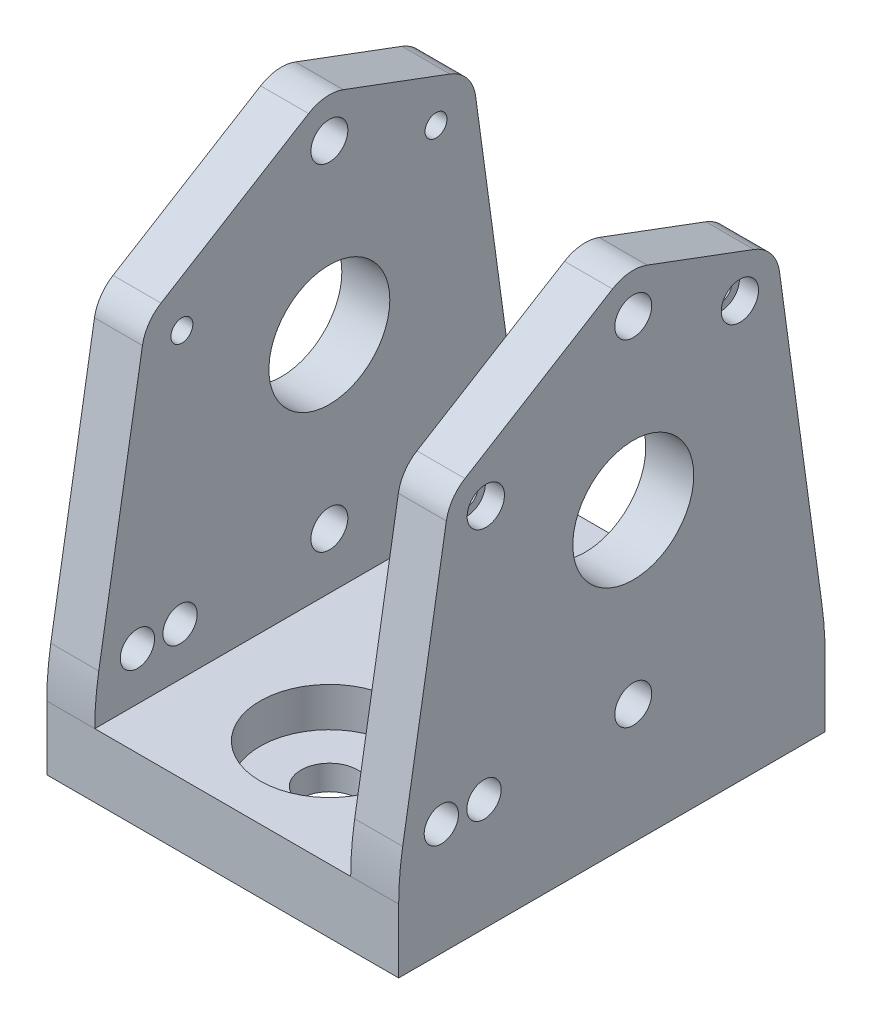
from build123d import *

# Parameters (mm, degrees)
BOSS_EXTRUDE1_DEPTH                           = 63.5
F_18_0_18_DIAMETER_HOLE1_D                    = 18
CBORE_FOR_4_SOCKET_HEAD_CAP_SCREW1_AT_2_COUNT = 2
CBORE_FOR_4_SOCKET_HEAD_CAP_SCREW1_AT_2_PITCH = 38.572873922
M5_CLEARANCE_HOLE1_D                          = 5.5
CBORE_FOR_5_16_HEX_MACHINE_SCREW1_D           = 8.4328
CBORE_FOR_5_16_HEX_MACHINE_SCREW1_CBORE_D     = 20.6375
CBORE_FOR_5_16_HEX_MACHINE_SCREW1_CBORE_DEPTH = 5.842
F_10_CLEARANCE_HOLE1_D                        = 5.1054
CUT_EXTRUDE1_DEPTH                            = 110.850526462
CUT_EXTRUDE1_DEPTH_BACK                       = 110.850526462


with BuildPart() as part:
    # Sketch1 → Boss-Extrude1 (new body)
    with BuildSketch(Plane.XY):
        Polygon((-26.19375, 0), (26.19375, 0), (26.19375, 9.525), (26.19375, 85.725), (19.05, 85.725), (19.05, 9.525), (-19.05, 9.525), (-19.05, 85.725), (-26.19375, 85.725), (-26.19375, 9.525), align=None)
    extrude(amount=BOSS_EXTRUDE1_DEPTH)

    # Ø18.0 (18) Diameter Hole1 (through all)
    with Locations(Plane(origin=(26.19375, 0, 0), x_dir=(0, 0, -1), z_dir=(1, 0, 0))):
        with Locations((-28.575, 42.8625)):
            Hole(F_18_0_18_DIAMETER_HOLE1_D / 2)

    # Sketch13 → CBORE for _4 Socket Head Cap Screw1 (revolve, cut)
    with BuildSketch(Plane(origin=(-26.19375, 61.9125, 12.7), x_dir=(0, 0, 1), z_dir=(0, 1, 0))):
        Polygon((0, 0), (0, 42.382574487), (1.63195, 41.402), (1.63195, 2.8448), (2.77876, 2.8448), (2.77876, 0), align=None)
    cbore_for_4_socket_head_cap_screw1 = revolve(axis=Axis((-32.54375, 61.9125, 12.7), (1, 0, 0)), mode=Mode.SUBTRACT)

    # CBORE for _4 Socket Head Cap Screw1 at 2: CBORE for _4 Socket Head Cap Screw1 ×2
    with Locations(*[Vector(0, -0.19509032201612558, 0.9807852804032311) * (i * CBORE_FOR_4_SOCKET_HEAD_CAP_SCREW1_AT_2_PITCH) for i in range(1, CBORE_FOR_4_SOCKET_HEAD_CAP_SCREW1_AT_2_COUNT)]):
        add(cbore_for_4_socket_head_cap_screw1, mode=Mode.SUBTRACT)

    # Mirror1: CBORE for _4 Socket Head Cap Screw1 across Right Plane
    add(cbore_for_4_socket_head_cap_screw1.mirror(Plane(origin=(0, 0, 0), x_dir=(0, 0, -1), z_dir=(1, 0, 0))), mode=Mode.SUBTRACT)

    # Mirror1 copy 1 sketch → Mirror1 copy 1 (revolve, cut)
    with BuildSketch(Plane(origin=(26.19375, 54.387305606, 50.531706965), x_dir=(0, 0, 1), z_dir=(0, 1, 0))):
        Polygon((0, 0), (0, -42.382574487), (1.63195, -41.402), (1.63195, -2.8448), (2.77876, -2.8448), (2.77876, 0), align=None)
    revolve(axis=Axis((32.54375, 54.387305606, 50.531706965), (1, 0, 0)), mode=Mode.SUBTRACT)

    # M5 Clearance Hole1 (through all)
    with Locations(Plane.ZY.offset(26.19375)):
        with Locations((28.575, 67.862500038), (28.575, 17.862499962)):
            m5_clearance_hole1 = Hole(M5_CLEARANCE_HOLE1_D / 2)

    # Mirror2: M5 Clearance Hole1 across plane
    add(m5_clearance_hole1.mirror(Plane(origin=(0, 0, 0), x_dir=(0, 0, 1), z_dir=(1, 0, 0))), mode=Mode.SUBTRACT)

    # CBORE for 5_16 Hex Machine Screw1 (through all)
    with Locations(Plane(origin=(0, 9.525, 0), x_dir=(1, 0, 0), z_dir=(0, 1, 0))):
        with Locations((0, -47.625), (0, -15.875)):
            CounterBoreHole(CBORE_FOR_5_16_HEX_MACHINE_SCREW1_D / 2, CBORE_FOR_5_16_HEX_MACHINE_SCREW1_CBORE_D / 2, CBORE_FOR_5_16_HEX_MACHINE_SCREW1_CBORE_DEPTH)

    # 10 Clearance Hole1 (through all)
    with Locations(Plane.ZY.offset(26.19375)):
        with Locations((57.15, 16.66875), (50.8, 16.66875)):
            Hole(F_10_CLEARANCE_HOLE1_D / 2)

    # Sketch33 → Cut-Extrude1 (cut, two sides: drawn at the far end of the back side and taken through both)
    with BuildSketch(Plane(origin=(0, 0, 0), x_dir=(0, 0, -1), z_dir=(1, 0, 0)).offset(-CUT_EXTRUDE1_DEPTH_BACK)):
        with BuildLine():
            Line((0, 9.525), (0, 85.725))
            Line((0, 85.725), (-63.5, 85.725))
            Line((-63.5, 85.725), (-63.5, 9.525))
            ThreePointArc((-63.5, 9.525), (-63.350798487, 13.109275044), (-62.904226292, 16.66875))
            Line((-62.904226292, 16.66875), (-56.403219724, 55.373508453))
            ThreePointArc((-56.403219724, 55.373508453), (-55.465840296, 57.719209927), (-53.640248783, 59.465122647))
            Line((-53.640248783, 59.465122647), (-31.668525817, 72.915788375))
            ThreePointArc((-31.668525817, 72.915788375), (-30.181999005, 73.565409751), (-28.575, 73.787500038))
            ThreePointArc((-28.575, 73.787500038), (-27.523281567, 73.693410202), (-26.504966009, 73.414129013))
            Line((-26.504966009, 73.414129013), (-10.619918046, 67.491076629))
            ThreePointArc((-10.619918046, 67.491076629), (-8.052135843, 65.633335513), (-6.80142126, 62.721219352))
            Line((-6.80142126, 62.721219352), (-0.487438724, 16.66875))
            ThreePointArc((-0.487438724, 16.66875), (-0.122001188, 13.105180183), (0, 9.525))
        make_face()
    extrude(amount=CUT_EXTRUDE1_DEPTH + CUT_EXTRUDE1_DEPTH_BACK, mode=Mode.SUBTRACT)


solid = part.part
